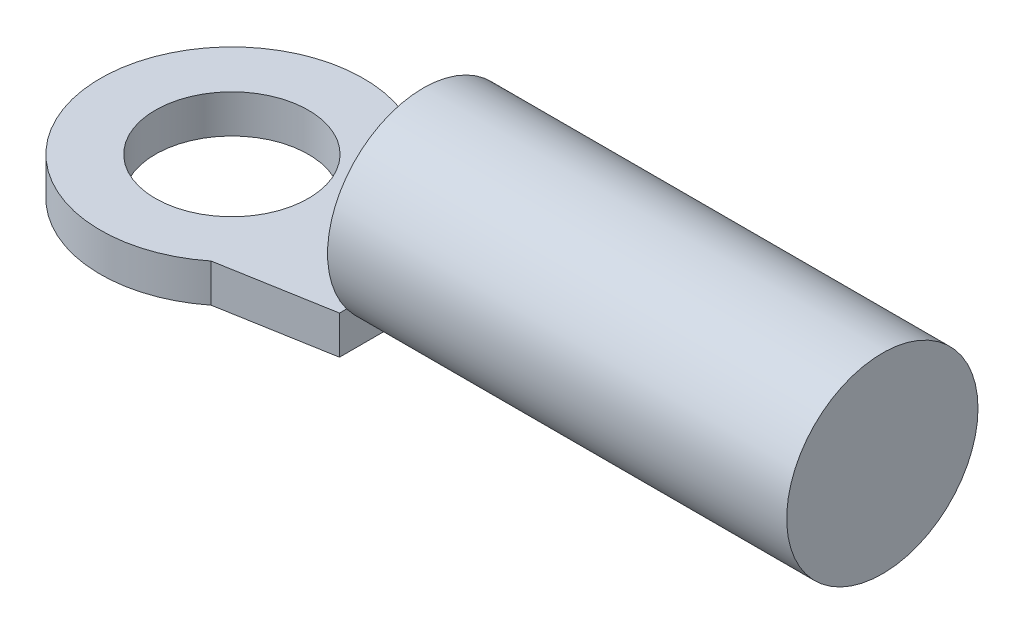
from build123d import *

# Parameters (mm, degrees)
SKETCH1_R           = 1.6
BOSS_EXTRUDE1_DEPTH = 0.8
SKETCH2_R           = 2
BOSS_EXTRUDE2_DEPTH = 9.6


with BuildPart() as part:
    # Sketch1 → Boss-Extrude1 (new body)
    with BuildSketch(Plane(origin=(0, 0, 0), x_dir=(1, 0, 0), z_dir=(0, 1, 0))):
        with BuildLine():
            ThreePointArc((1.71464282, 2.15), (-2.75, 0), (1.71464282, -2.15))
            Line((1.71464282, -2.15), (4, -1.75))
            Line((4, -1.75), (4, 1.75))
            Line((4, 1.75), (1.71464282, 2.15))
        make_face()
        Circle(SKETCH1_R, mode=Mode.SUBTRACT)
    extrude(amount=BOSS_EXTRUDE1_DEPTH)

    # Sketch2 → Boss-Extrude2 (add)
    with BuildSketch(Plane(origin=(4, 0, 0), x_dir=(0, 0, -1), z_dir=(1, 0, 0))):
        with Locations((0, 2)):
            Circle(SKETCH2_R)
    extrude(amount=BOSS_EXTRUDE2_DEPTH)


solid = part.part
